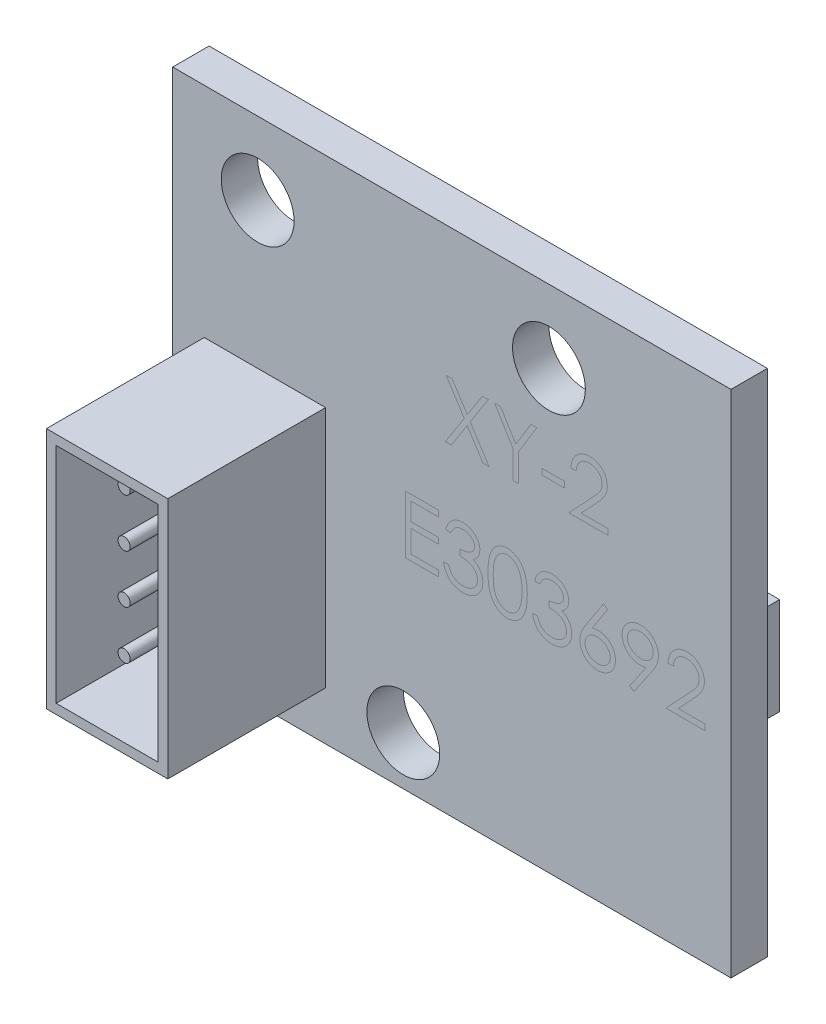
from build123d import *

# Parameters (mm, degrees)
ESQUISSE1_W             = 23
ESQUISSE1_H             = 21
BOSS_EXTRU_1_DEPTH      = 1.5
ESQUISSE2_R             = 0.25
BOSS_EXTRU_2_DEPTH      = 5
BOSS_EXTRU_2_2_DEPTH    = 5
BOSS_EXTRU_2_3_DEPTH    = 5
BOSS_EXTRU_2_4_DEPTH    = 5
ESQUISSE3_R             = 1.5
ENL_V_MAT_EXTRU_1_DEPTH = 17.355427234
ESQUISSE5_W             = 5
ESQUISSE5_H             = 10
ESQUISSE5_W_2           = 4.2
ESQUISSE5_H_2           = 9.2
BOSS_EXTRU_3_DEPTH      = 6.5
ESQUISSE6_W             = 5
ESQUISSE6_H             = 4
BOSS_EXTRU_4_DEPTH      = 1.5
BOSS_EXTRU_4_2_DEPTH    = 1.5
ESQUISSE6_W_2           = 3
ESQUISSE6_H_2           = 2
BOSS_EXTRU_4_3_DEPTH    = 1.5


with BuildPart() as part:
    # Esquisse1 → Boss.-Extru.1 (new body)
    with BuildSketch(Plane.XY):
        Rectangle(ESQUISSE1_W, ESQUISSE1_H)
    extrude(amount=BOSS_EXTRU_1_DEPTH)

    # Esquisse3 → Enlèv. mat.-Extru.1 (cut, through all)
    with BuildSketch(Plane.XY.offset(1.5)):
        with Locations((-8, 7.5)):
            Circle(ESQUISSE3_R)
        with Locations((4, 7.5)):
            Circle(ESQUISSE3_R)
        with Locations((-2, -8.5)):
            Circle(ESQUISSE3_R)
    extrude(amount=-ENL_V_MAT_EXTRU_1_DEPTH, mode=Mode.SUBTRACT)


with BuildPart() as body_2:
    # Esquisse2 → Boss.-Extru.2 (new body)
    with BuildSketch(Plane.XY.offset(1.5)):
        with Locations((-8.5, -0.5)):
            Circle(ESQUISSE2_R)
    extrude(amount=BOSS_EXTRU_2_DEPTH)


    add(part.part)  # Boss.-Extru.3 merges part


with BuildPart() as body_3:
    # Esquisse2 → Boss.-Extru.2 2 (new body)
    with BuildSketch(Plane.XY.offset(1.5)):
        with Locations((-8.5, -2.5)):
            Circle(ESQUISSE2_R)
    extrude(amount=BOSS_EXTRU_2_2_DEPTH)


with BuildPart() as body_4:
    # Esquisse2 → Boss.-Extru.2 3 (new body)
    with BuildSketch(Plane.XY.offset(1.5)):
        with Locations((-8.5, -4.5)):
            Circle(ESQUISSE2_R)
    extrude(amount=BOSS_EXTRU_2_3_DEPTH)


with BuildPart() as body_5:
    # Esquisse2 → Boss.-Extru.2 4 (new body)
    with BuildSketch(Plane.XY.offset(1.5)):
        with Locations((-8.5, -6.5)):
            Circle(ESQUISSE2_R)
    extrude(amount=BOSS_EXTRU_2_4_DEPTH)


with BuildPart() as body_2_1:
    add(body_2.part)

    add(body_3.part)  # Boss.-Extru.3 merges body 3

    add(body_4.part)  # Boss.-Extru.3 merges body 4

    add(body_5.part)  # Boss.-Extru.3 merges body 5
    # Esquisse5 → Boss.-Extru.3 (add)
    with BuildSketch(Plane.XY.offset(1.5)):
        with Locations((-7.7, -3.5)):
            Rectangle(ESQUISSE5_W, ESQUISSE5_H)
        with Locations((-7.7, -3.5)):
            Rectangle(ESQUISSE5_W_2, ESQUISSE5_H_2, mode=Mode.SUBTRACT)
    extrude(amount=BOSS_EXTRU_3_DEPTH)


with BuildPart() as body_2_2:
    # Esquisse6 → Boss.-Extru.4 (new body)
    with BuildSketch(Plane(origin=(0, 0, 0), x_dir=(-1, 0, 0), z_dir=(0, 0, -1))):
        with Locations((-8, -1)):
            Rectangle(ESQUISSE6_W, ESQUISSE6_H)
    extrude(amount=BOSS_EXTRU_4_DEPTH)


with BuildPart() as body_3_2:
    # Esquisse6 → Boss.-Extru.4 2 (new body)
    with BuildSketch(Plane(origin=(0, 0, 0), x_dir=(-1, 0, 0), z_dir=(0, 0, -1))):
        with Locations((2, 1.5)):
            Rectangle(ESQUISSE6_W, ESQUISSE6_H)
    extrude(amount=BOSS_EXTRU_4_2_DEPTH)


with BuildPart() as body_4_2:
    # Esquisse6 → Boss.-Extru.4 3 (new body)
    with BuildSketch(Plane(origin=(0, 0, 0), x_dir=(-1, 0, 0), z_dir=(0, 0, -1))):
        with Locations((9, 2.5)):
            Rectangle(ESQUISSE6_W_2, ESQUISSE6_H_2)
    extrude(amount=BOSS_EXTRU_4_3_DEPTH)


solid = Compound([body_2_1.part, body_2_2.part, body_3_2.part, body_4_2.part])
